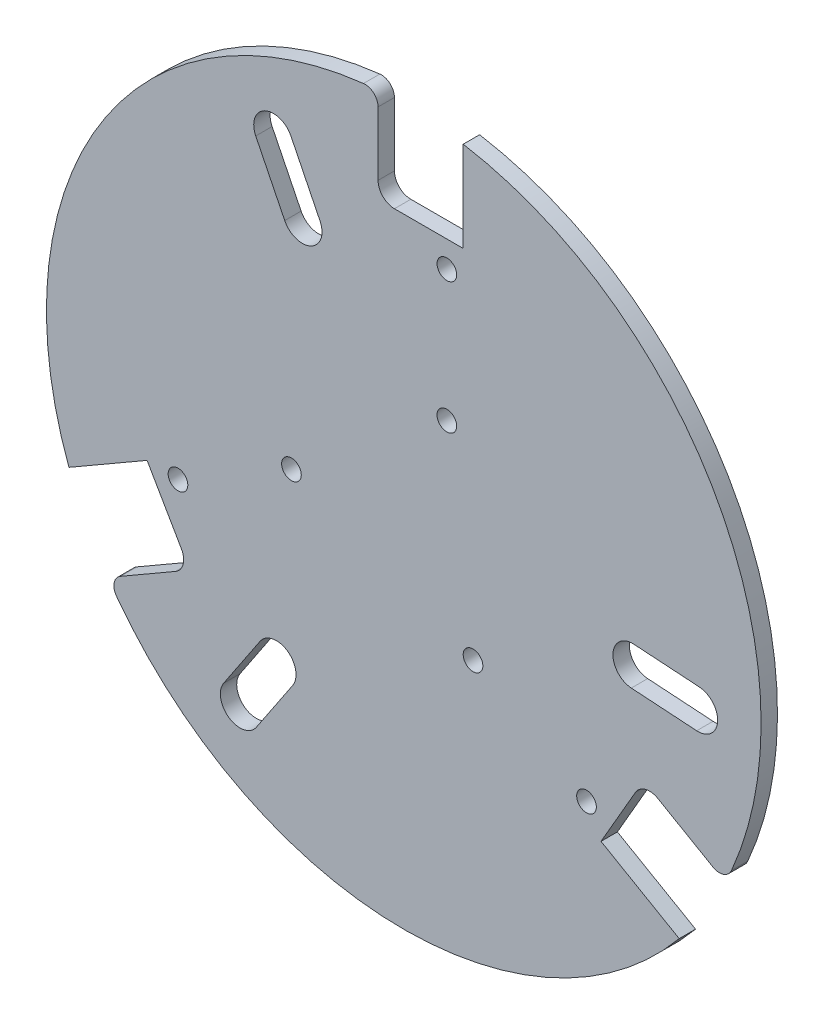
from build123d import *

# Parameters (mm, degrees)
SKETCH1_R           = 1.905
BOSS_EXTRUDE1_DEPTH = 3.175
FILLET1_R           = 2.54


with BuildPart() as part:
    # Sketch1 → Boss-Extrude1 (new body)
    with BuildSketch(Plane.XY):
        with BuildLine():
            Line((-64.912044694, -24.170240567), (-49.756080512, -15.419940567))
            Line((-49.756080512, -15.419940567), (-46.581080512, -20.919201881))
            Line((-46.581080512, -20.919201881), (-43.088580512, -26.968389327))
            ThreePointArc((-43.088580512, -26.968389327), (-42.771396671, -29.377639795), (-44.250711169, -31.305519984))
            Line((-44.250711169, -31.305519984), (-57.337460999, -38.861158521))
            ThreePointArc((-57.337460999, -38.861158521), (-3.292499409, -69.187668866), (53.388064694, -44.130359433))
            Line((53.388064694, -44.130359433), (38.232100512, -35.380059433))
            Line((38.232100512, -35.380059433), (41.407100512, -29.880798119))
            Line((41.407100512, -29.880798119), (44.899600512, -23.831610673))
            ThreePointArc((44.899600512, -23.831610673), (46.827480701, -22.352296175), (49.236731169, -22.669480016))
            Line((49.236731169, -22.669480016), (62.323480999, -30.225118553))
            ThreePointArc((62.323480999, -30.225118553), (61.564528571, 31.742446303), (11.52398, 68.3006))
            Line((11.52398, 68.3006), (11.52398, 50.8))
            Line((11.52398, 50.8), (5.17398, 50.8))
            Line((5.17398, 50.8), (-1.81102, 50.8))
            ThreePointArc((-1.81102, 50.8), (-4.05608403, 51.72993597), (-4.98602, 53.975))
            Line((-4.98602, 53.975), (-4.98602, 69.086277074))
            ThreePointArc((-4.98602, 69.086277074), (-58.272029162, 37.445222563), (-64.912044694, -24.170240567))
        make_face()
        with Locations((-43.769171461, -15.629571224)):
            Circle(SKETCH1_R, mode=Mode.SUBTRACT)
        with Locations((-21.772126205, -2.929571224)):
            Circle(SKETCH1_R, mode=Mode.SUBTRACT)
        with Locations((13.423146205, -17.390428776)):
            Circle(SKETCH1_R, mode=Mode.SUBTRACT)
        with Locations((35.420191461, -30.090428776)):
            Circle(SKETCH1_R, mode=Mode.SUBTRACT)
        with Locations((8.34898, 45.72)):
            Circle(SKETCH1_R, mode=Mode.SUBTRACT)
        with Locations((8.34898, 20.32)):
            Circle(SKETCH1_R, mode=Mode.SUBTRACT)
        with BuildLine():
            Line((-21.860648036, 52.941011205), (-16.243380607, 41.550826544))
            ThreePointArc((-16.243380607, 41.550826544), (-17.975255776, 36.448590916), (-23.077491403, 38.180466086))
            Line((-23.077491403, 38.180466086), (-28.694758833, 49.570650747))
            ThreePointArc((-28.694758833, 49.570650747), (-26.962883664, 54.672886375), (-21.860648036, 52.941011205))
        make_face(mode=Mode.SUBTRACT)
        with BuildLine():
            Line((56.778584624, -7.53862906), (44.105761638, -6.708233023))
            ThreePointArc((44.105761638, -6.708233023), (40.553033554, -2.657267317), (44.60399926, 0.895460768))
            Line((44.60399926, 0.895460768), (57.276822246, 0.065064732))
            ThreePointArc((57.276822246, 0.065064732), (60.829550331, -3.985900975), (56.778584624, -7.53862906))
        make_face(mode=Mode.SUBTRACT)
        with BuildLine():
            Line((-34.917936587, -45.402382145), (-27.862381032, -34.84259352))
            ThreePointArc((-27.862381032, -34.84259352), (-22.577777778, -33.7913236), (-21.526507857, -39.075926854))
            Line((-21.526507857, -39.075926854), (-28.582063413, -49.635715479))
            ThreePointArc((-28.582063413, -49.635715479), (-33.866666667, -50.686985399), (-34.917936587, -45.402382145))
        make_face(mode=Mode.SUBTRACT)
    extrude(amount=BOSS_EXTRUDE1_DEPTH)

    # Fillet1
    fillet1_edges = [part.edges().sort_by_distance(p)[0] for p in [
        (-4.98602, 69.086277074, 1.5875),
        (62.323480999, -30.225118553, 1.5875),
        (-57.337460999, -38.861158521, 1.5875),
    ]]
    fillet(fillet1_edges, radius=FILLET1_R)


solid = part.part
